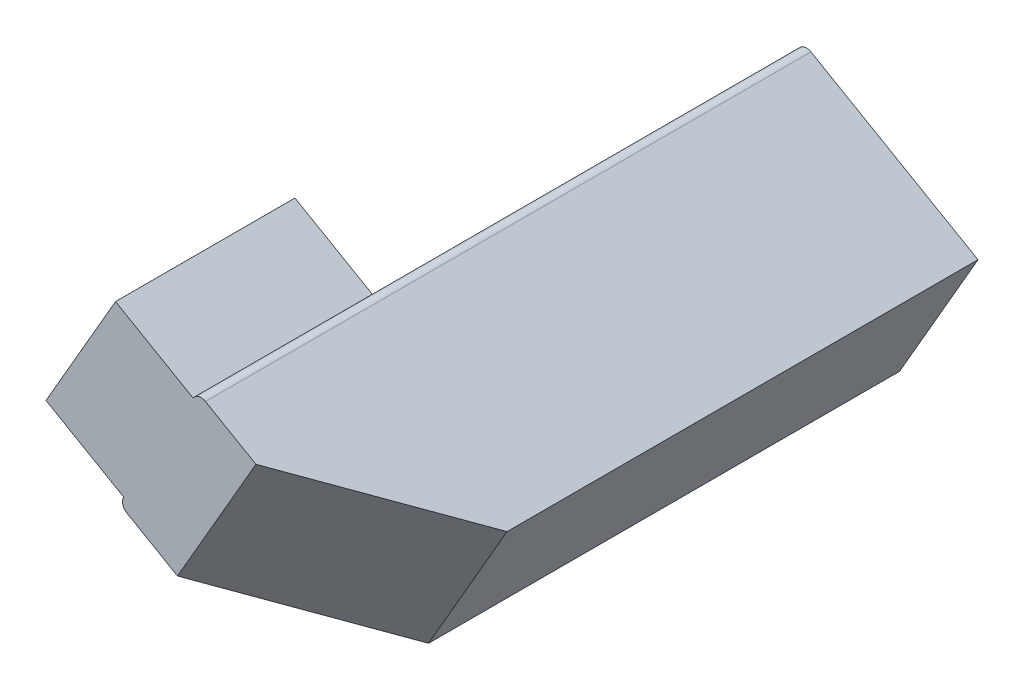
from build123d import *

# Parameters (mm, degrees)
BOSS_EXTRUDE1_DEPTH = 135
SKETCH3_W           = 40
SKETCH3_H           = 31
BOSS_EXTRUDE2_DEPTH = 20
CHAMFER1_SIZE       = 30


with BuildPart() as part:
    # Sketch2 → Boss-Extrude1 (new body)
    with BuildSketch(Plane.XY):
        with BuildLine():
            Line((114.838111964, -46.094555434), (77.599019601, -24.594555434))
            ThreePointArc((77.599019601, -24.594555434), (76.081381511, -24.394754589), (74.866968793, -25.326606241))
            Line((74.866968793, -25.326606241), (59.366968793, -52.173393759))
            ThreePointArc((59.366968793, -52.173393759), (59.167167948, -53.691031849), (60.099019601, -54.905444566))
            Line((60.099019601, -54.905444566), (97.338111964, -76.405444566))
            Line((97.338111964, -76.405444566), (114.838111964, -46.094555434))
        make_face()
    extrude(amount=BOSS_EXTRUDE1_DEPTH)

    # Sketch3 → Boss-Extrude2 (add)
    with BuildSketch(Plane(origin=(67.116968793, -38.75, 0), x_dir=(0, 0, 1), z_dir=(-0.866025404, 0.5, 0))):
        with Locations((115, 0)):
            Rectangle(SKETCH3_W, SKETCH3_H)
    extrude(amount=BOSS_EXTRUDE2_DEPTH)

    # Chamfer1
    chamfer1_edges = [part.edges().sort_by_distance(p)[0] for p in [
        (106.088111964, -61.25, 135),
    ]]
    chamfer(chamfer1_edges, length=CHAMFER1_SIZE)


solid = part.part
